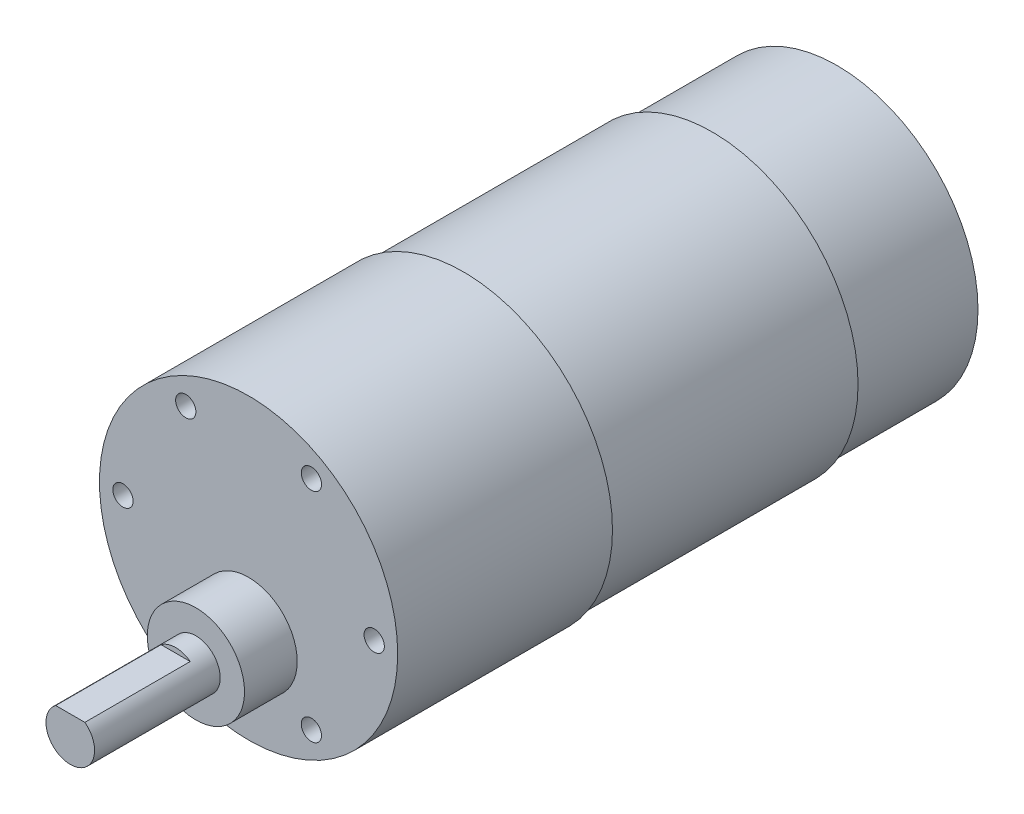
from build123d import *

# Parameters (mm, degrees)
SKETCH1_R                       = 17.4
BOSS_EXTRUDE1_DEPTH             = 15.4
SKETCH2_R                       = 18
BOSS_EXTRUDE2_DEPTH             = 30.7
SKETCH3_R                       = 18.4
BOSS_EXTRUDE3_DEPTH             = 26.5
SKETCH4_R                       = 6
BOSS_EXTRUDE4_DEPTH             = 6.5
SKETCH5_R                       = 3
BOSS_EXTRUDE5_DEPTH             = 15.5
CUT_EXTRUDE1_DEPTH              = 13
TAP_DRILL_FOR_M3X0_5_TAP1_D     = 2.5
TAP_DRILL_FOR_M3X0_5_TAP1_DEPTH = 10.76


with BuildPart() as part:
    # Sketch1 → Boss-Extrude1 (new body)
    with BuildSketch(Plane.XY):
        Circle(SKETCH1_R)
    extrude(amount=BOSS_EXTRUDE1_DEPTH)

    # Sketch2 → Boss-Extrude2 (add)
    with BuildSketch(Plane.XY.offset(15.4)):
        Circle(SKETCH2_R)
    extrude(amount=BOSS_EXTRUDE2_DEPTH)

    # Sketch3 → Boss-Extrude3 (add)
    with BuildSketch(Plane.XY.offset(46.1)):
        Circle(SKETCH3_R)
    extrude(amount=BOSS_EXTRUDE3_DEPTH)

    # Sketch4 → Boss-Extrude4 (add)
    with BuildSketch(Plane.XY.offset(72.6)):
        with Locations((0, -7)):
            Circle(SKETCH4_R)
    extrude(amount=BOSS_EXTRUDE4_DEPTH)

    # Sketch5 → Boss-Extrude5 (add)
    with BuildSketch(Plane.XY.offset(79.1)):
        with Locations((0, -7)):
            Circle(SKETCH5_R)
    extrude(amount=BOSS_EXTRUDE5_DEPTH)

    # Sketch6 → Cut-Extrude1 (cut)
    with BuildSketch(Plane.XY.offset(94.6)):
        with BuildLine():
            Line((-1.8, -4.6), (1.8, -4.6))
            ThreePointArc((1.8, -4.6), (0, -4), (-1.8, -4.6))
        make_face()
    extrude(amount=-CUT_EXTRUDE1_DEPTH, mode=Mode.SUBTRACT)

    # Tap Drill for M3x0.5 Tap1
    with Locations(Plane.XY.offset(72.6)):
        with Locations((-15.5, 0), (-7.75, 13.423393759), (7.75, 13.423393759), (15.5, 0), (7.75, -13.423393759), (-7.75, -13.423393759)):
            Hole(TAP_DRILL_FOR_M3X0_5_TAP1_D / 2, depth=TAP_DRILL_FOR_M3X0_5_TAP1_DEPTH)


solid = part.part
